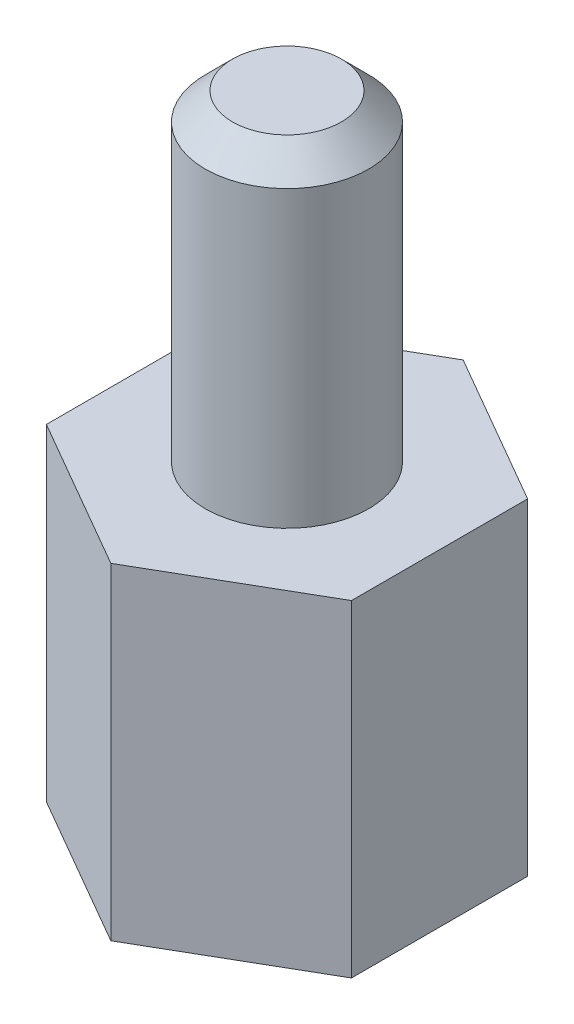
from build123d import *

# Parameters (mm, degrees)
BOSS_EXTRUDE1_DEPTH = 6
SKETCH2_R           = 1.5
BOSS_EXTRUDE2_DEPTH = 5.9
SKETCH3_R           = 1.5
CUT_EXTRUDE1_DEPTH  = 4
CHAMFER1_SIZE       = 0.5


with BuildPart() as part:
    # Sketch1 → Boss-Extrude1 (new body)
    with BuildSketch(Plane(origin=(0, 0, 0), x_dir=(1, 0, 0), z_dir=(0, 1, 0))):
        Polygon((0, -3.233161507), (2.8, -1.616580754), (2.8, 1.616580754), (0, 3.233161507), (-2.8, 1.616580754), (-2.8, -1.616580754), align=None)
    extrude(amount=BOSS_EXTRUDE1_DEPTH)

    # Sketch2 → Boss-Extrude2 (add)
    with BuildSketch(Plane(origin=(0, 6, 0), x_dir=(1, 0, 0), z_dir=(0, 1, 0))):
        Circle(SKETCH2_R)
    extrude(amount=BOSS_EXTRUDE2_DEPTH)

    # Sketch3 → Cut-Extrude1 (cut)
    with BuildSketch(Plane.XZ):
        Circle(SKETCH3_R)
    extrude(amount=-CUT_EXTRUDE1_DEPTH, mode=Mode.SUBTRACT)

    # Chamfer1
    chamfer1_edges = [part.edges().sort_by_distance(p)[0] for p in [
        (-1.5, 11.9, 0),
    ]]
    chamfer(chamfer1_edges, length=CHAMFER1_SIZE)


solid = part.part
